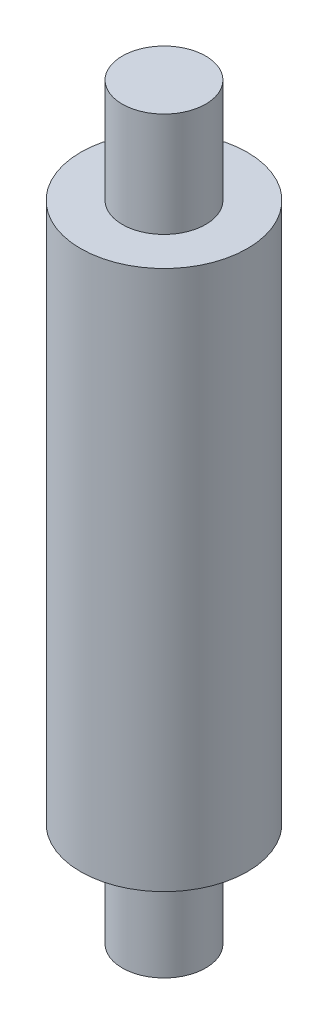
from build123d import *

# Parameters (mm, degrees)
SKETCH1_W = 3.4544
SKETCH1_H = 30.988
SKETCH2_W = 1.7272
SKETCH2_H = 4.318
SKETCH3_W = 1.7272
SKETCH3_H = 4.318


with BuildPart() as part:
    # Sketch1 → Revolve1 (revolve)
    with BuildSketch(Plane.XY):
        with Locations((1.7272, 15.494)):
            Rectangle(SKETCH1_W, SKETCH1_H)
    revolve(axis=Axis((0, 0, 0), (0, 1, 0)))

    # Sketch2 → Cut-Revolve1 (revolve, cut)
    with BuildSketch(Plane.XY):
        with Locations((2.5908, 2.159)):
            Rectangle(SKETCH2_W, SKETCH2_H)
    revolve(axis=Axis((0, 0, 0), (0, 1, 0)), mode=Mode.SUBTRACT)

    # Sketch3 → Cut-Revolve2 (revolve, cut)
    with BuildSketch(Plane.XY):
        with Locations((2.5908, 28.829)):
            Rectangle(SKETCH3_W, SKETCH3_H)
    revolve(axis=Axis((0, 26.67, 0), (0, 1, 0)), mode=Mode.SUBTRACT)


solid = part.part
